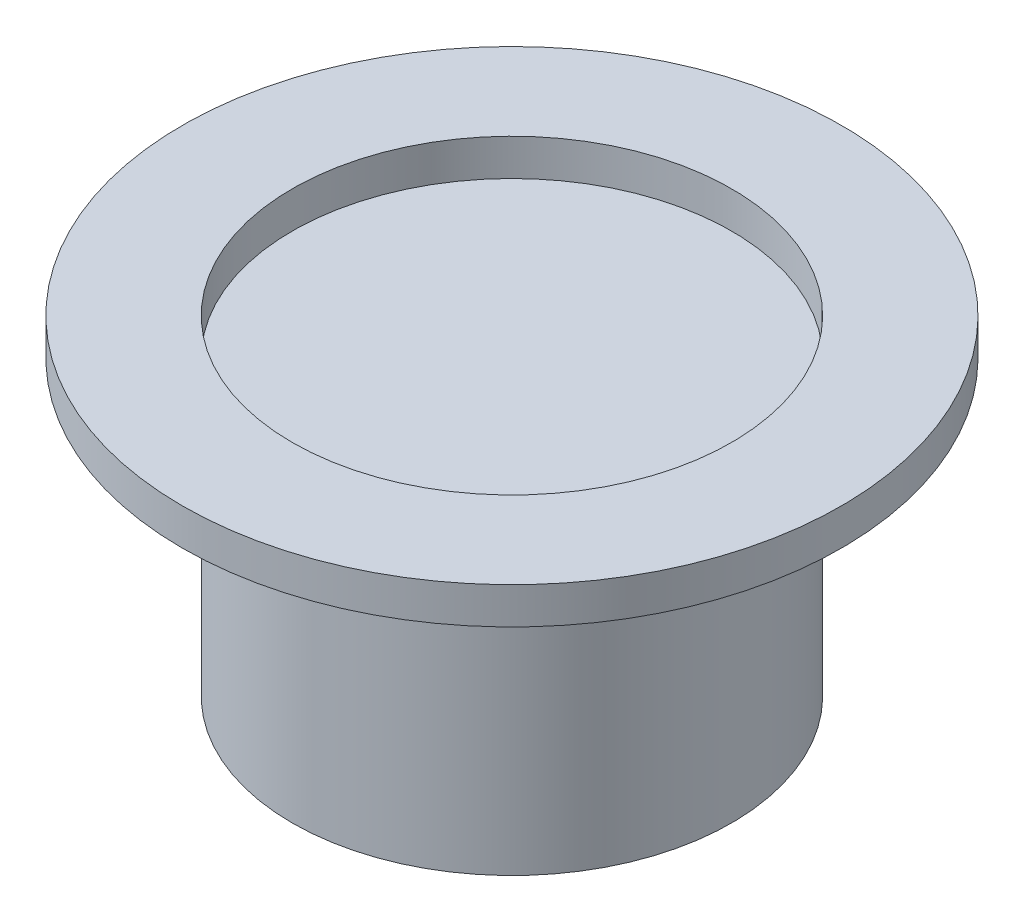
from build123d import *

# Parameters (mm, degrees)
CROQUIS1_R              = 3
SALIENTE_EXTRUIR1_DEPTH = 4
CROQUIS2_R              = 4.5
CROQUIS2_R_2            = 3
SALIENTE_EXTRUIR2_DEPTH = 0.5


with BuildPart() as part:
    # Croquis1 → Saliente-Extruir1 (new body)
    with BuildSketch(Plane(origin=(0, 0, 0), x_dir=(1, 0, 0), z_dir=(0, 1, 0))):
        Circle(CROQUIS1_R)
    extrude(amount=SALIENTE_EXTRUIR1_DEPTH)


with BuildPart() as body_2:
    # Croquis2 → Saliente-Extruir2 (new body)
    with BuildSketch(Plane(origin=(0, 4, 0), x_dir=(1, 0, 0), z_dir=(0, 1, 0))):
        Circle(CROQUIS2_R)
        Circle(CROQUIS2_R_2, mode=Mode.SUBTRACT)
    extrude(amount=SALIENTE_EXTRUIR2_DEPTH)


solid = Compound([part.part, body_2.part])
